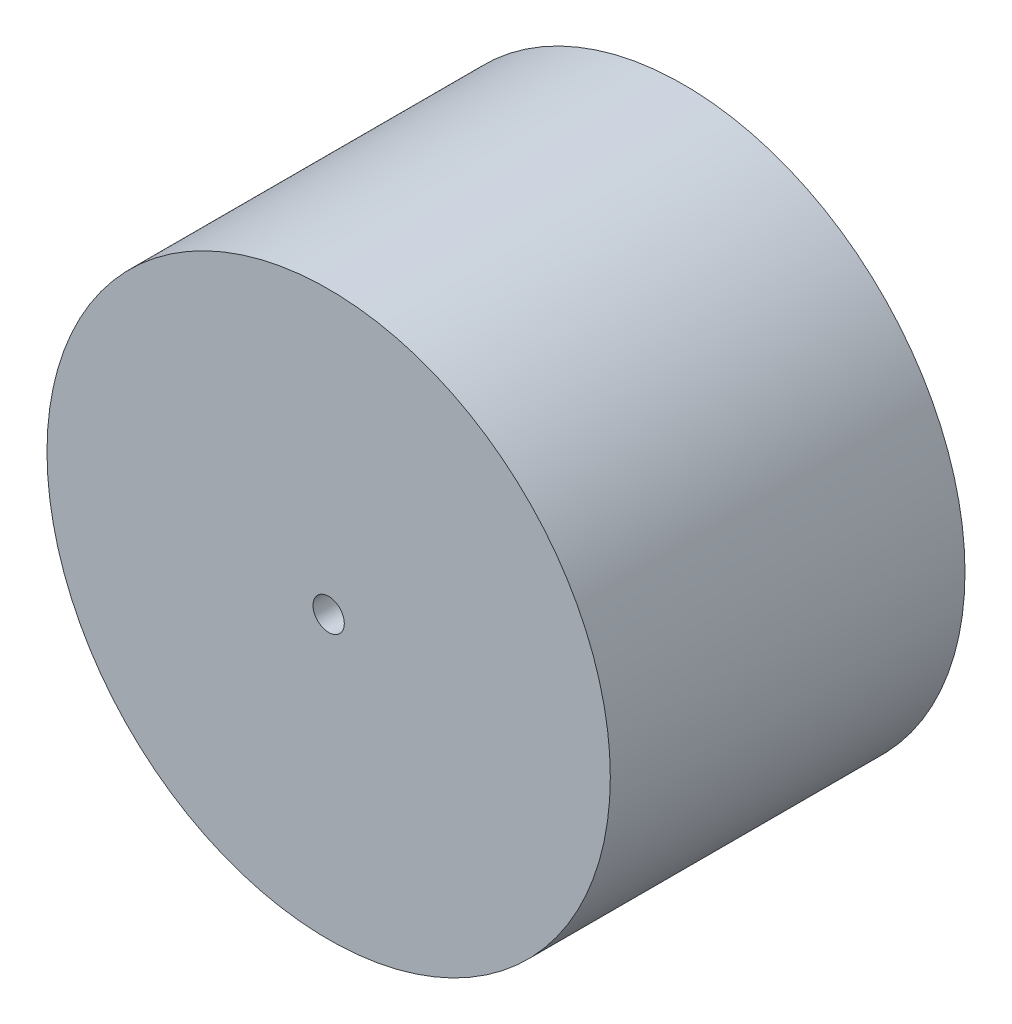
from build123d import *

# Parameters (mm, degrees)
CROQUIS1_R              = 27
CROQUIS1_R_2            = 1.5
SALIENTE_EXTRUIR1_DEPTH = 34


with BuildPart() as part:
    # Croquis1 → Saliente-Extruir1 (new body)
    with BuildSketch(Plane.XY):
        Circle(CROQUIS1_R)
        Circle(CROQUIS1_R_2, mode=Mode.SUBTRACT)
    extrude(amount=SALIENTE_EXTRUIR1_DEPTH)


solid = part.part
